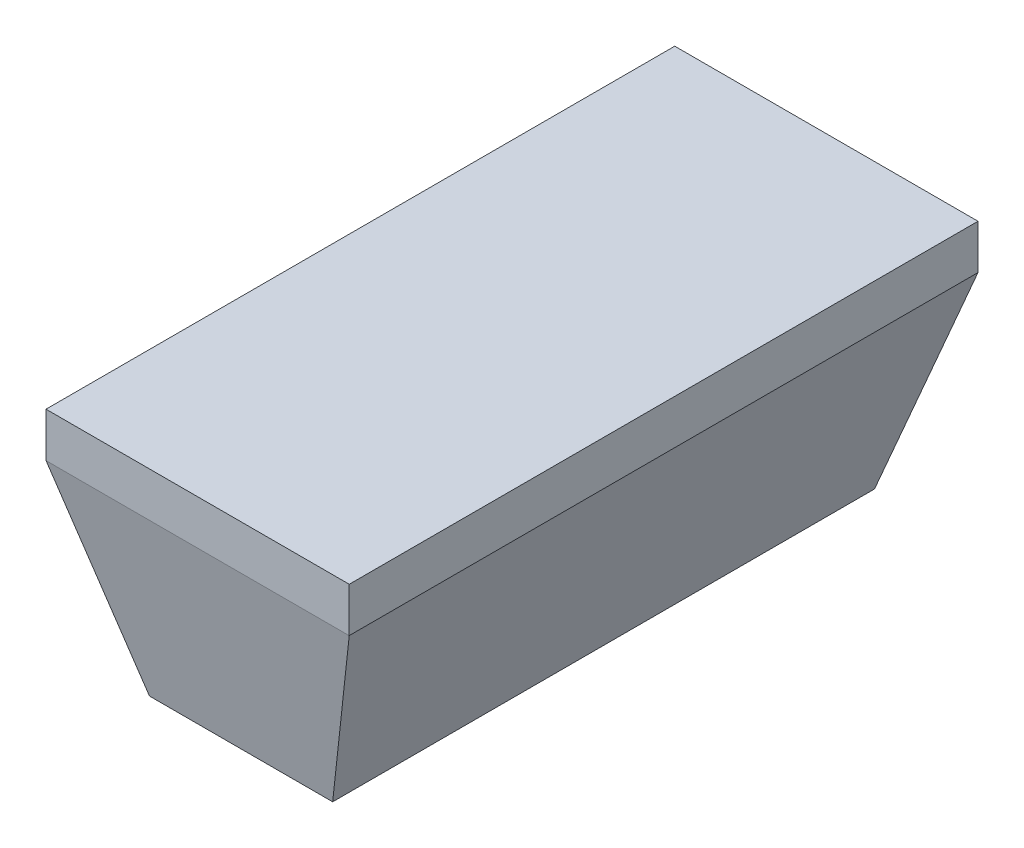
from build123d import *

# Parameters (mm, degrees)
ESTRUSIONE_ESTRUSIONE1_DEPTH      = 10
ESTRUSIONE_ESTRUSIONE1_DEPTH_BACK = 10
SCHIZZO3_OUTSIDE_W                = 27.366
SCHIZZO3_OUTSIDE_H                = 13.749
TAGLIO_ESTRUSIONE2_DEPTH          = 9.355
TAGLIO_ESTRUSIONE2_DEPTH_BACK     = 9.355


with BuildPart() as part:
    # Schizzo2 → Estrusione-Estrusione1 (new body, two sides)
    with BuildSketch(Plane(origin=(0, 0, 0), x_dir=(0, 0, -1), z_dir=(1, 0, 0))) as estrusione_estrusione1_sk:
        Polygon((-7.200336343, -5.2), (7.199751527, -5.2), (8.355, 0), (8.355, 1.182571265), (-8.355, 1.182571265), (-8.355, 0), align=None)
    extrude(amount=ESTRUSIONE_ESTRUSIONE1_DEPTH)
    extrude(estrusione_estrusione1_sk.sketch, amount=-ESTRUSIONE_ESTRUSIONE1_DEPTH_BACK)

    # Schizzo3 outside → Taglio-Estrusione2 (cut, two sides)
    with BuildSketch(Plane.XY) as taglio_estrusione2_sk:
        with Locations((0, -2.0085)):
            Rectangle(SCHIZZO3_OUTSIDE_W, SCHIZZO3_OUTSIDE_H)
        Polygon((2.434296655, -5.201208291), (-2.434296655, -5.201208291), (-4.029664932, 0.001330674), (-4.029664932, 1.658816204), (4.029664932, 1.658816204), (4.029664932, 0.001330674), align=None, mode=Mode.SUBTRACT)
    extrude(amount=TAGLIO_ESTRUSIONE2_DEPTH, mode=Mode.SUBTRACT)
    extrude(taglio_estrusione2_sk.sketch, amount=-TAGLIO_ESTRUSIONE2_DEPTH_BACK, mode=Mode.SUBTRACT)


solid = part.part
